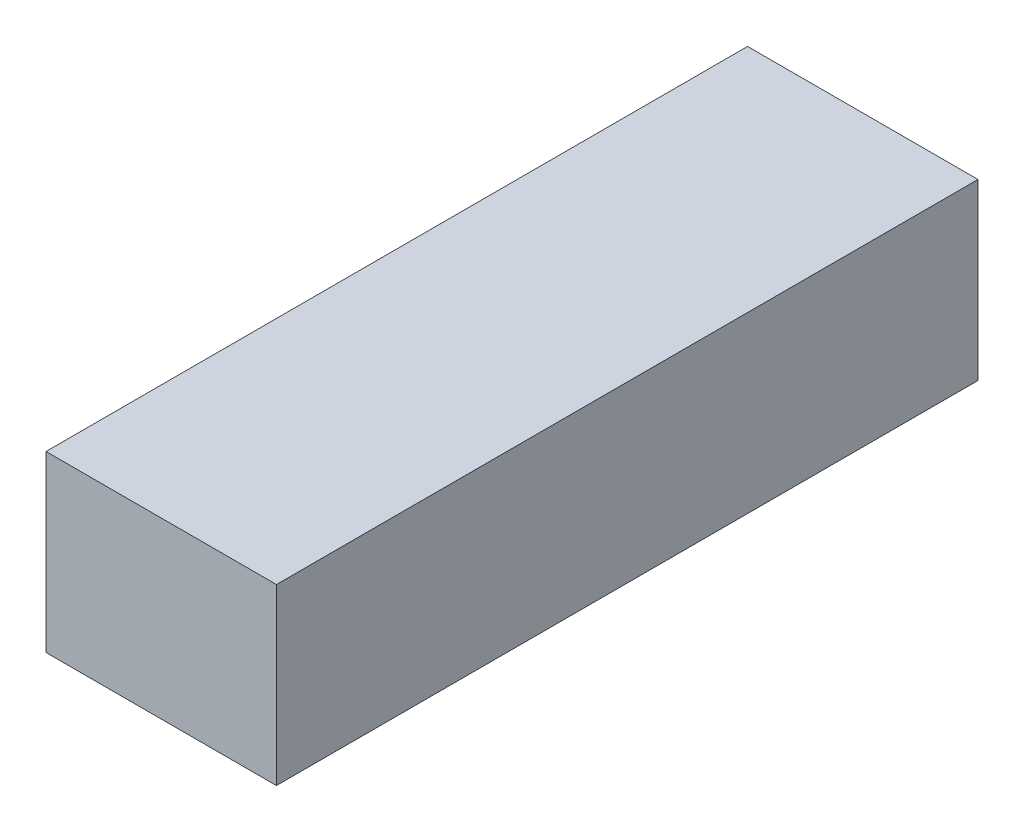
from build123d import *

# Parameters (mm, degrees)
SKETCH1_W           = 45
SKETCH1_H           = 34
BOSS_EXTRUDE1_DEPTH = 137


with BuildPart() as part:
    # Sketch1 → Boss-Extrude1 (new body)
    with BuildSketch(Plane.XY):
        Rectangle(SKETCH1_W, SKETCH1_H)
    extrude(amount=BOSS_EXTRUDE1_DEPTH)


solid = part.part
